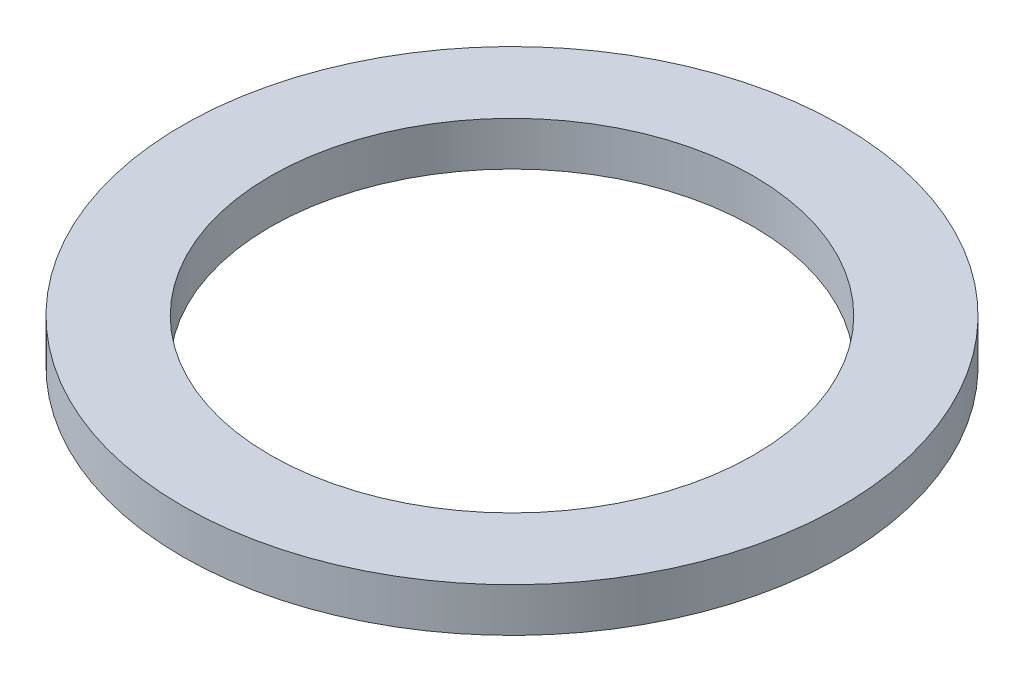
from build123d import *

# Parameters (mm, degrees)
SKETCH1_R           = 3.75
SKETCH1_R_2         = 2.75
BOSS_EXTRUDE1_DEPTH = 0.5


with BuildPart() as part:
    # Sketch1 → Boss-Extrude1 (new body)
    with BuildSketch(Plane(origin=(0, 0, 0), x_dir=(1, 0, 0), z_dir=(0, 1, 0))):
        Circle(SKETCH1_R)
        Circle(SKETCH1_R_2, mode=Mode.SUBTRACT)
    extrude(amount=BOSS_EXTRUDE1_DEPTH)


solid = part.part
